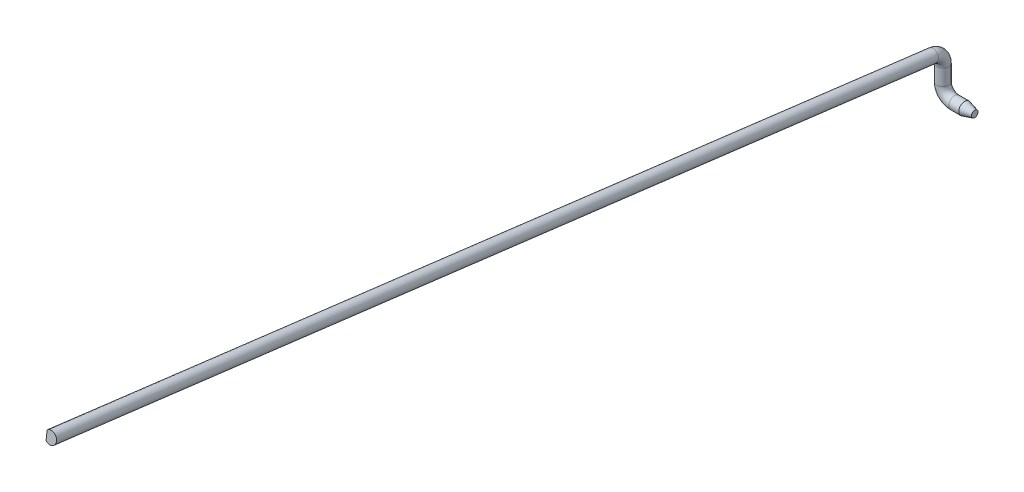
from build123d import *

# Parameters (mm, degrees)
SKETCH2_R          = 1.5
SKETCH4_R          = 1.5
CHAMFER1_SIZE      = 2.5
CHAMFER1_SIZE2     = 0.669872981
CUT_EXTRUDE1_DEPTH = 1.5000001


with BuildPart() as part:
    # Sweep1: sweep along a path in Sketch1
    with BuildLine(Plane(origin=(0, 0, 0), x_dir=(0, 0, -1), z_dir=(1, 0, 0))) as sweep1_path:
        Line((0, 0), (0, 2))
        ThreePointArc((0, 2), (-0.751070943, 3.985527158), (-2.628212063, 4.976873146))
        Line((-2.628212063, 4.976873146), (-219, 32))
        Line((-219, 32), (-223.961455244, 32.619646562))
    # Sketch2 → Sweep1 (sweep)
    with BuildSketch(Plane(origin=(0, 0, 0), x_dir=(1, 0, 0), z_dir=(0, 1, 0))):
        Circle(SKETCH2_R)
    sweep(path=sweep1_path.line)

    # Sweep2: sweep along a path in Sketch3
    with BuildLine(Plane.XY) as sweep2_path:
        Line((0, 0), (0, -2))
        ThreePointArc((0, -2), (0.878679656, -4.121320344), (3, -5))
        Line((3, -5), (8, -5))
    # Sketch4 → Sweep2 (sweep)
    with BuildSketch(Plane.XZ):
        Circle(SKETCH4_R)
    sweep(path=sweep2_path.line)

    # Chamfer1
    chamfer1_edges = [part.edges().sort_by_distance(p)[0] for p in [
        (8, -6.5, 0),
    ]]
    chamfer1_side = [part.faces().sort_by_distance(p)[0] for p in [
        (5.5, -6.5, 0),
    ]]
    chamfer(chamfer1_edges, length=CHAMFER1_SIZE, length2=CHAMFER1_SIZE2, reference=chamfer1_side[0])

    # Sketch5 → Cut-Extrude1 (cut, through all)
    with BuildSketch(Plane(origin=(-1, 0, 0), x_dir=(0, 0, -1), z_dir=(1, 0, 0))):
        Polygon((-224.209313869, 30.635064464), (-223.713596619, 34.604228659), (-208.829230887, 32.745288974), (-209.324948137, 28.776124779), align=None)
    extrude(amount=-CUT_EXTRUDE1_DEPTH, mode=Mode.SUBTRACT)


solid = part.part
